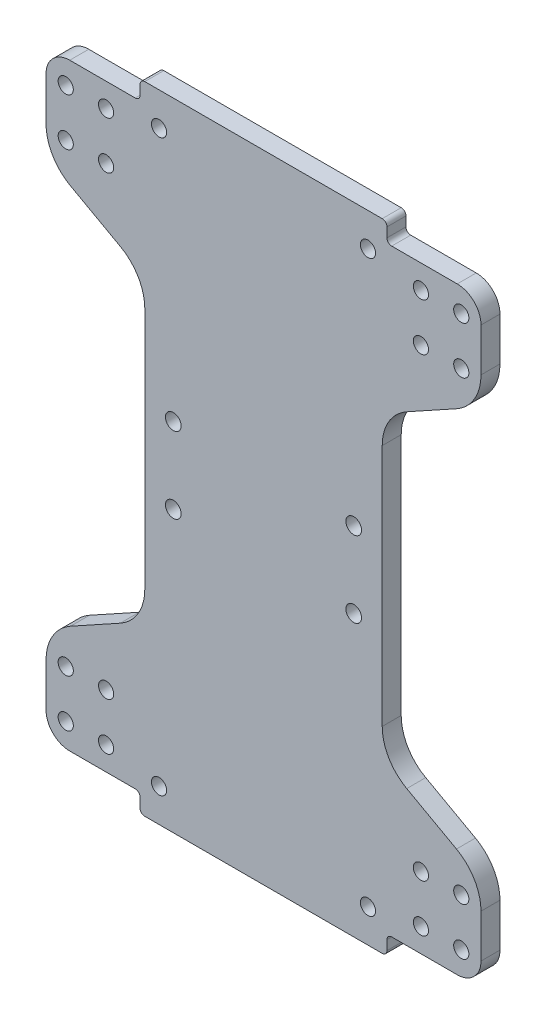
from build123d import *

# Parameters (mm, degrees)
SKETCH1_R           = 1.6
SKETCH1_R_2         = 1.65
BOSS_EXTRUDE1_DEPTH = 4
FILLET2_R           = 10
FILLET3_R           = 5


with BuildPart() as part:
    # Sketch1 → Boss-Extrude1 (new body)
    with BuildSketch(Plane.XY):
        with BuildLine():
            Line((1.40773023, -0.063608297), (20.206941284, -0.063608297))
            ThreePointArc((20.206941284, -0.063608297), (20.914048066, -0.356501516), (21.206941284, -1.063608297))
            Line((21.206941284, -1.063608297), (21.206941284, -3.063608297))
            ThreePointArc((21.206941284, -3.063608297), (21.499834503, -3.770715079), (22.206941284, -4.063608297))
            Line((22.206941284, -4.063608297), (72.208519176, -4.063608297))
            ThreePointArc((72.208519176, -4.063608297), (72.915625957, -3.770715079), (73.208519176, -3.063608297))
            Line((73.208519176, -3.063608297), (73.208519176, -1.063608297))
            ThreePointArc((73.208519176, -1.063608297), (73.501412395, -0.356501516), (74.208519176, -0.063608297))
            Line((74.208519176, -0.063608297), (93.00773023, -0.063608297))
            Line((93.00773023, -0.063608297), (93.00773023, 19.936391703))
            Line((93.00773023, 19.936391703), (72.20773023, 31.430017028))
            Line((72.20773023, 31.430017028), (72.20773023, 94.442766377))
            Line((72.20773023, 94.442766377), (93.00773023, 105.936391703))
            Line((93.00773023, 105.936391703), (93.00773023, 125.936391703))
            Line((93.00773023, 125.936391703), (74.208519176, 125.936391703))
            ThreePointArc((74.208519176, 125.936391703), (73.501412395, 126.229284921), (73.208519176, 126.936391703))
            Line((73.208519176, 126.936391703), (73.208519176, 128.936391703))
            ThreePointArc((73.208519176, 128.936391703), (72.915625957, 129.643498484), (72.208519176, 129.936391703))
            Line((72.208519176, 129.936391703), (22.206941284, 129.936391703))
            ThreePointArc((22.206941284, 129.936391703), (21.499834503, 129.643498484), (21.206941284, 128.936391703))
            Line((21.206941284, 128.936391703), (21.206941284, 126.936391703))
            ThreePointArc((21.206941284, 126.936391703), (20.914048066, 126.229284921), (20.206941284, 125.936391703))
            Line((20.206941284, 125.936391703), (1.40773023, 125.936391703))
            Line((1.40773023, 125.936391703), (1.40773023, 105.936391703))
            Line((1.40773023, 105.936391703), (22.20773023, 94.442766377))
            Line((22.20773023, 94.442766377), (22.20773023, 31.430017028))
            Line((22.20773023, 31.430017028), (1.40773023, 19.936391703))
            Line((1.40773023, 19.936391703), (1.40773023, -0.063608297))
        make_face()
        with Locations((5.55773023, 4.936391703)):
            Circle(SKETCH1_R, mode=Mode.SUBTRACT)
        with Locations((14.05773023, 4.936391703)):
            Circle(SKETCH1_R, mode=Mode.SUBTRACT)
        with Locations((14.05773023, 14.936391703)):
            Circle(SKETCH1_R, mode=Mode.SUBTRACT)
        with Locations((5.55773023, 14.936391703)):
            Circle(SKETCH1_R, mode=Mode.SUBTRACT)
        with Locations((69.208519176, 2.936391703)):
            Circle(SKETCH1_R, mode=Mode.SUBTRACT)
        with Locations((66.20773023, 54.936391703)):
            Circle(SKETCH1_R_2, mode=Mode.SUBTRACT)
        with Locations((88.85773023, 14.936391703)):
            Circle(SKETCH1_R, mode=Mode.SUBTRACT)
        with Locations((80.35773023, 14.936391703)):
            Circle(SKETCH1_R, mode=Mode.SUBTRACT)
        with Locations((80.35773023, 4.936391703)):
            Circle(SKETCH1_R, mode=Mode.SUBTRACT)
        with Locations((88.85773023, 4.936391703)):
            Circle(SKETCH1_R, mode=Mode.SUBTRACT)
        with Locations((28.20773023, 54.936391703)):
            Circle(SKETCH1_R_2, mode=Mode.SUBTRACT)
        with Locations((25.206941284, 2.936391703)):
            Circle(SKETCH1_R, mode=Mode.SUBTRACT)
        with Locations((25.206941284, 122.936391703)):
            Circle(SKETCH1_R, mode=Mode.SUBTRACT)
        with Locations((28.20773023, 70.936391703)):
            Circle(SKETCH1_R_2, mode=Mode.SUBTRACT)
        with Locations((88.85773023, 120.936391703)):
            Circle(SKETCH1_R, mode=Mode.SUBTRACT)
        with Locations((80.35773023, 120.936391703)):
            Circle(SKETCH1_R, mode=Mode.SUBTRACT)
        with Locations((80.35773023, 110.936391703)):
            Circle(SKETCH1_R, mode=Mode.SUBTRACT)
        with Locations((88.85773023, 110.936391703)):
            Circle(SKETCH1_R, mode=Mode.SUBTRACT)
        with Locations((66.20773023, 70.936391703)):
            Circle(SKETCH1_R_2, mode=Mode.SUBTRACT)
        with Locations((69.208519176, 122.936391703)):
            Circle(SKETCH1_R, mode=Mode.SUBTRACT)
        with Locations((5.55773023, 110.936391703)):
            Circle(SKETCH1_R, mode=Mode.SUBTRACT)
        with Locations((14.05773023, 110.936391703)):
            Circle(SKETCH1_R, mode=Mode.SUBTRACT)
        with Locations((14.05773023, 120.936391703)):
            Circle(SKETCH1_R, mode=Mode.SUBTRACT)
        with Locations((5.55773023, 120.936391703)):
            Circle(SKETCH1_R, mode=Mode.SUBTRACT)
    extrude(amount=BOSS_EXTRUDE1_DEPTH)

    # Fillet2
    fillet2_edges = [part.edges().sort_by_distance(p)[0] for p in [
        (1.40773023, 19.936391703, 2),
        (22.20773023, 31.430017028, 2),
        (22.20773023, 94.442766377, 2),
        (1.40773023, 105.936391703, 2),
        (93.00773023, 105.936391703, 2),
        (72.20773023, 94.442766377, 2),
        (72.20773023, 31.430017028, 2),
        (93.00773023, 19.936391703, 2),
    ]]
    fillet(fillet2_edges, radius=FILLET2_R)

    # Fillet3
    fillet3_edges = [part.edges().sort_by_distance(p)[0] for p in [
        (1.40773023, 125.936391703, 2),
        (93.00773023, 125.936391703, 2),
        (93.00773023, -0.063608297, 2),
        (1.40773023, -0.063608297, 2),
    ]]
    fillet(fillet3_edges, radius=FILLET3_R)


solid = part.part
